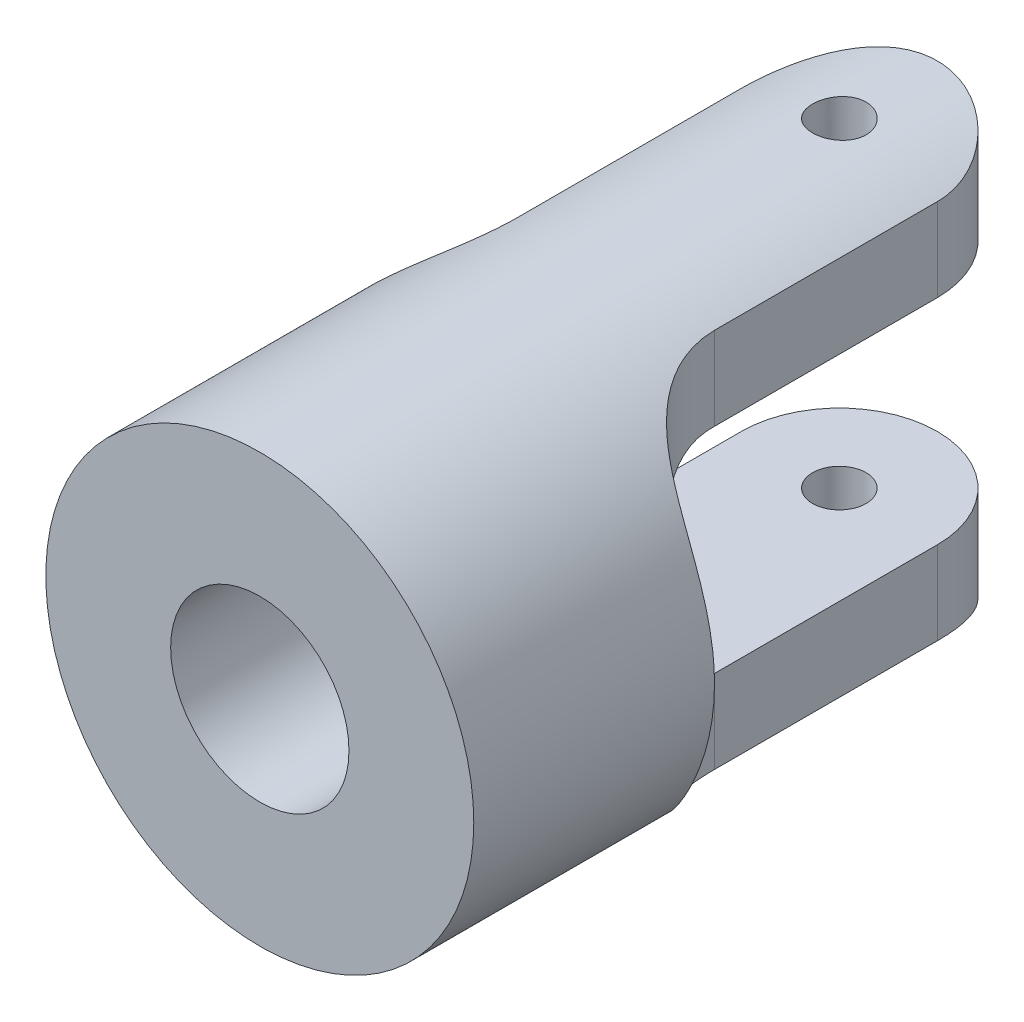
from build123d import *

# Parameters (mm, degrees)
SKETCH_1_R          = 6
SKETCH_1_R_2        = 2.5
EXTRUDE_1_DEPTH     = 19
SKETCH_2_OUTSIDE_W  = 19.096
SKETCH_2_OUTSIDE_H  = 26.096
SKETCH_2_OUTSIDE_R  = 0.75
CUT_EXTRUDE_1_DEPTH = 9.5
CUT_EXTRUDE_2_DEPTH = 9.5


with BuildPart() as part:
    # 草图1 → 凸台-拉伸1 (new body)
    with BuildSketch(Plane.XY):
        Circle(SKETCH_1_R)
        Circle(SKETCH_1_R_2, mode=Mode.SUBTRACT)
    extrude(amount=EXTRUDE_1_DEPTH)

    # 草图2 outside → 切除-拉伸1 (cut, symmetric)
    with BuildSketch(Plane(origin=(0, 0, 0), x_dir=(1, 0, 0), z_dir=(0, 1, 0))):
        with Locations((0, -9.5)):
            Rectangle(SKETCH_2_OUTSIDE_W, SKETCH_2_OUTSIDE_H)
        with BuildLine():
            Line((-2.75, -2.75), (-2.75, -9))
            ThreePointArc((-2.75, -9), (-3.701902961, -11.298097039), (-6, -12.25))
            Line((-6, -12.25), (-6, -19))
            Line((-6, -19), (6, -19))
            Line((6, -19), (6, -12.25))
            ThreePointArc((6, -12.25), (3.701902961, -11.298097039), (2.75, -9))
            Line((2.75, -9), (2.75, -2.75))
            ThreePointArc((2.75, -2.75), (0, 0), (-2.75, -2.75))
        make_face(mode=Mode.SUBTRACT)
        with Locations((0, -2.75)):
            Circle(SKETCH_2_OUTSIDE_R)
    extrude(amount=CUT_EXTRUDE_1_DEPTH, both=True, mode=Mode.SUBTRACT)

    # 草图3 → 切除-拉伸2 (cut, symmetric)
    with BuildSketch(Plane(origin=(0, 0, 0), x_dir=(0, 0, -1), z_dir=(1, 0, 0))):
        with BuildLine():
            Line((-9.250000001, 3), (0, 3))
            Line((0, 3), (0, -3))
            Line((0, -3), (-9.250000001, -3))
            ThreePointArc((-9.250000001, -3), (-12.250000001, 0), (-9.250000001, 3))
        make_face()
    extrude(amount=CUT_EXTRUDE_2_DEPTH, both=True, mode=Mode.SUBTRACT)


solid = part.part
